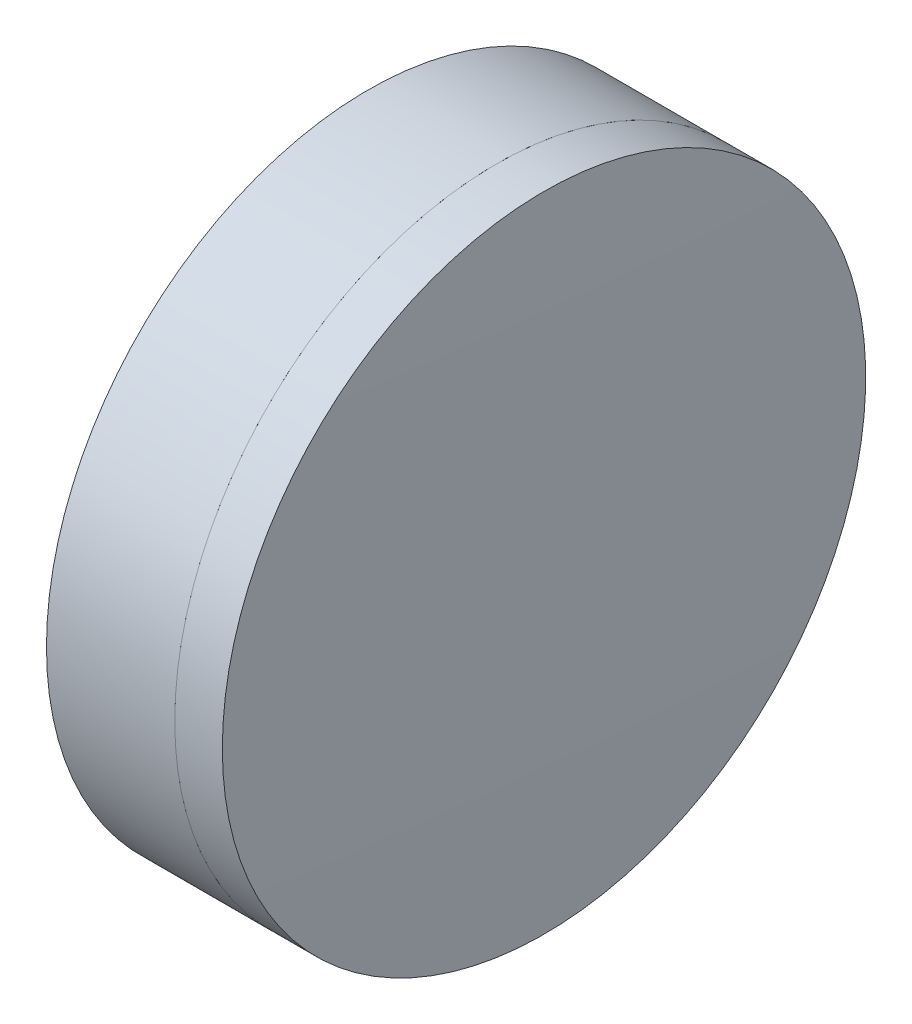
from build123d import *


with BuildPart() as part:
    # 草图1 one side → 旋转1 (revolve)
    with BuildSketch(Plane(origin=(0, 0, 0), x_dir=(1, 0, 0), z_dir=(0, 1, 0)), mode=Mode.PRIVATE) as revolve_1_sk:
        with BuildLine():
            Line((146.171829849, 12.7), (141.107222163, 12.7))
            ThreePointArc((141.107222163, 12.7), (142.366544932, 6.405418621), (142.788754446, 0))
            Line((142.788754446, 0), (144.788754446, 0))
            ThreePointArc((144.788754446, 0), (145.135542466, 6.387544473), (146.171829849, 12.7))
        make_face()
    revolve(revolve_1_sk.sketch.rotate(Axis((-185.274474051, 0, 0), (1, 0, 0)), 180), axis=Axis((-185.274474051, 0, 0), (1, 0, 0)))  # turned: the seam where the file's is


with BuildPart() as body_2:
    # 草图2 one side → 旋转3 (revolve)
    with BuildSketch(Plane(origin=(0, 0, 0), x_dir=(1, 0, 0), z_dir=(0, 1, 0)), mode=Mode.PRIVATE) as revolve_3_sk:
        with BuildLine():
            Line((148.049886261, 12.7), (146.171829849, 12.7))
            ThreePointArc((146.171829849, 12.7), (145.135542466, 6.387544473), (144.788754446, 0))
            Line((144.788754446, 0), (148.188754446, 0))
            ThreePointArc((148.188754446, 0), (148.154036362, 6.350379602), (148.049886261, 12.7))
        make_face()
    revolve(revolve_3_sk.sketch.rotate(Axis((141.107222163, 0, 0), (1, 0, 0)), 180), axis=Axis((141.107222163, 0, 0), (1, 0, 0)))  # turned: the seam where the file's is


solid = Compound([part.part, body_2.part])
